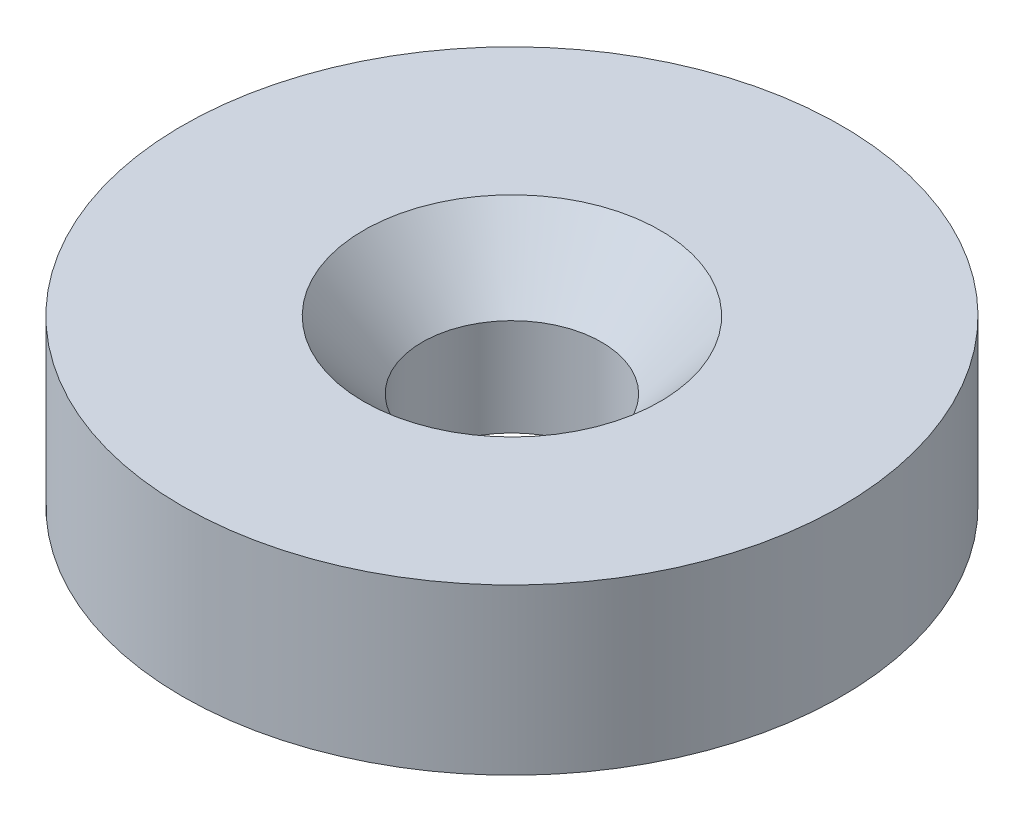
from build123d import *

# Parameters (mm, degrees)
SKETCH1_R           = 6.35
BOSS_EXTRUDE1_DEPTH = 3.175


with BuildPart() as part:
    # Sketch1 → Boss-Extrude1 (new body)
    with BuildSketch(Plane(origin=(0, 0, 0), x_dir=(1, 0, 0), z_dir=(0, 1, 0))):
        Circle(SKETCH1_R)
    extrude(amount=BOSS_EXTRUDE1_DEPTH)

    # Sketch3 → CSK for #4 Flat Head Machine Screw1 (revolve, cut)
    with BuildSketch(Plane(origin=(0, 3.175, 0), x_dir=(0, 0, 1), z_dir=(1, 0, 0))):
        Polygon((0, 0), (0, 3.175), (1.7272, 3.175), (1.7272, 1.300261411), (2.8575, 0), align=None)
    revolve(axis=Axis((0, 9.525, 0), (0, -1, 0)), mode=Mode.SUBTRACT)


solid = part.part
